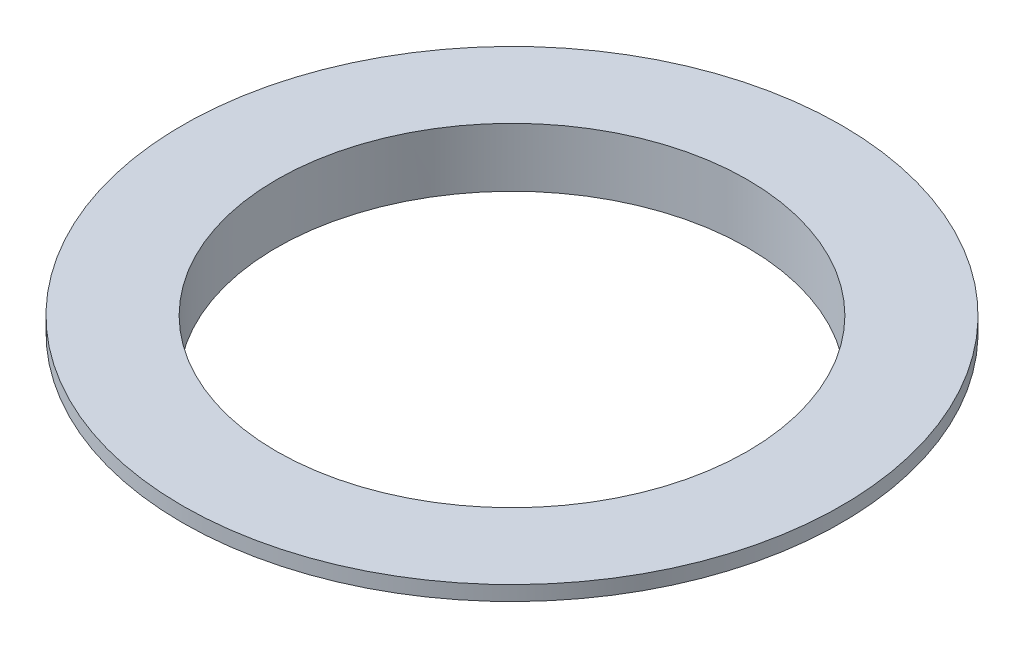
from build123d import *

# Parameters (mm, degrees)
SKETCH4_R          = 50.8
CUT_EXTRUDE1_DEPTH = 13.7


with BuildPart() as part:
    # Sketch1 → Revolve1 (revolve)
    with BuildSketch(Plane(origin=(0, 0, 0), x_dir=(0, 0, -1), z_dir=(1, 0, 0))):
        Polygon((50.8, 0), (57.15, 0), (57.15, 9.525), (71.12, 9.525), (71.12, 12.7), (0, 12.7), (0, 9.525), (50.8, 9.525), align=None)
    revolve(axis=Axis((0, 0, 0), (0, 1, 0)))

    # Sketch4 → Cut-Extrude1 (cut, through all)
    with BuildSketch(Plane(origin=(0, 12.7, 0), x_dir=(1, 0, 0), z_dir=(0, 1, 0))):
        Circle(SKETCH4_R)
    extrude(amount=-CUT_EXTRUDE1_DEPTH, mode=Mode.SUBTRACT)


solid = part.part
